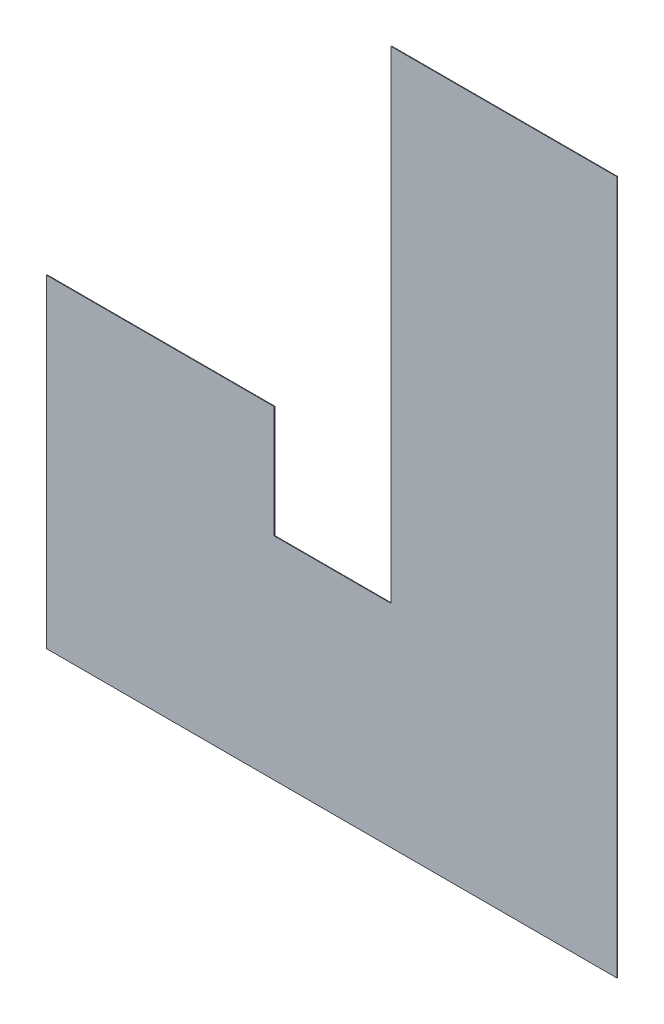
from build123d import *

# Parameters (mm, degrees)
SKETCH1_W           = 7610
SKETCH1_H           = 23390
BOSS_EXTRUDE1_DEPTH = 20


with BuildPart() as part:
    # Sketch1 → Boss-Extrude1 (new body)
    with BuildSketch(Plane.XY.offset(43822.979549141)):
        with Locations((-11801.617683291, -8387.518633414)):
            Rectangle(SKETCH1_W, SKETCH1_H)
        Polygon((-15606.617683291, -20082.518633414), (-15606.617683291, -12952.114633414), (-19546.617683291, -12952.114633414), (-27221.617683291, -12952.114633414), (-27221.617683291, -20082.518633414), align=None)
        Polygon((-27221.617683291, -12952.114633414), (-19546.617683291, -12952.114633414), (-19546.617683291, -12882.518633414), (-19546.617683291, -9177.114633414), (-27221.617683291, -9177.114633414), align=None)
    extrude(amount=BOSS_EXTRUDE1_DEPTH)


solid = part.part
